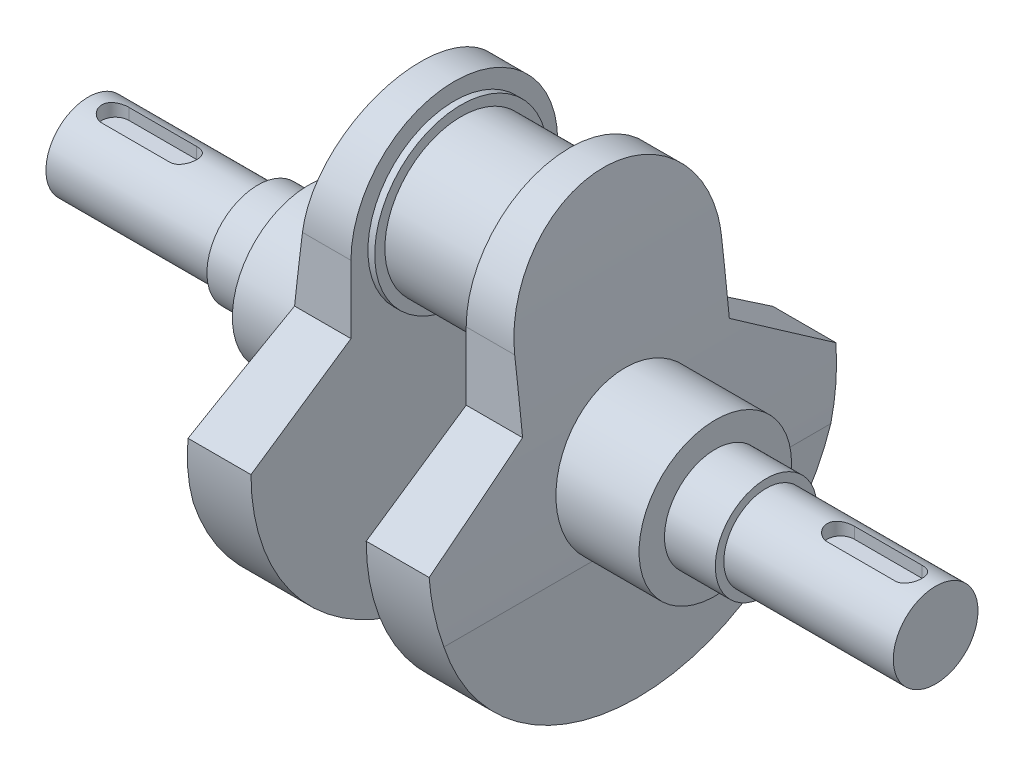
from build123d import *

# Parameters (mm, degrees)
SKETCH1_R           = 22.5
BOSS_EXTRUDE1_DEPTH = 15
SKETCH2_R           = 25.5
BOSS_EXTRUDE2_DEPTH = 2
BOSS_EXTRUDE3_DEPTH = 20
CUT_EXTRUDE1_DEPTH  = 99
BOSS_EXTRUDE4_REACH = 77
SKETCH5_R           = 22.5
SKETCH6_R           = 15
BOSS_EXTRUDE5_DEPTH = 15
SKETCH7_R           = 12.5
BOSS_EXTRUDE6_DEPTH = 50
CUT_EXTRUDE2_DEPTH  = 4


with BuildPart() as part:
    # Sketch1 → Boss-Extrude1 (new body, symmetric)
    with BuildSketch(Plane(origin=(0, 0, 0), x_dir=(0, 0, -1), z_dir=(1, 0, 0))):
        Circle(SKETCH1_R)
    extrude(amount=BOSS_EXTRUDE1_DEPTH, both=True)

    # Sketch2 → Boss-Extrude2 (add)
    with BuildSketch(Plane(origin=(15, 0, 0), x_dir=(0, 0, -1), z_dir=(1, 0, 0))):
        Circle(SKETCH2_R)
    extrude(amount=BOSS_EXTRUDE2_DEPTH)

    # Sketch3 → Boss-Extrude3 (add)
    with BuildSketch(Plane(origin=(17, 0, 0), x_dir=(0, 0, -1), z_dir=(1, 0, 0))):
        with BuildLine():
            Line((-30.5, 0), (-30.5, -20))
            Line((-30.5, -20), (-60, -40))
            ThreePointArc((-60, -40), (0, -100), (60, -40))
            Line((60, -40), (30.5, -20))
            Line((30.5, -20), (30.5, 0))
            ThreePointArc((30.5, 0), (0, 30.5), (-30.5, 0))
        make_face()
    extrude(amount=BOSS_EXTRUDE3_DEPTH)

    # Sketch4 → Cut-Extrude1 (cut, symmetric)
    with BuildSketch(Plane.XY):
        with BuildLine():
            Line((27, 30.5), (37, 30.5))
            Line((37, 30.5), (37, -58.5))
            ThreePointArc((37, -58.5), (32.963579083, -13.891732687), (27, 30.5))
        make_face()
    extrude(amount=CUT_EXTRUDE1_DEPTH, both=True, mode=Mode.SUBTRACT)

    # Sketch5 → Boss-Extrude4 (add, up to next)
    with BuildSketch(Plane(origin=(60, 0, 0), x_dir=(0, 0, -1), z_dir=(1, 0, 0)), mode=Mode.PRIVATE) as boss_extrude4_sk1:
        with Locations((0, -40)):
            Circle(SKETCH5_R)
    boss_extrude4_tool1 = extrude(boss_extrude4_sk1.sketch, amount=-BOSS_EXTRUDE4_REACH, mode=Mode.PRIVATE) - part.part
    add(boss_extrude4_tool1.solids().sort_by_distance((60, -40, 0))[0])

    # Sketch6 → Boss-Extrude5 (add)
    with BuildSketch(Plane(origin=(60, 0, 0), x_dir=(0, 0, -1), z_dir=(1, 0, 0))):
        with Locations((0, -40)):
            Circle(SKETCH6_R)
    extrude(amount=BOSS_EXTRUDE5_DEPTH)

    # Sketch7 → Boss-Extrude6 (add)
    with BuildSketch(Plane(origin=(75, 0, 0), x_dir=(0, 0, -1), z_dir=(1, 0, 0))):
        with Locations((0, -40)):
            Circle(SKETCH7_R)
    extrude(amount=BOSS_EXTRUDE6_DEPTH)

    # Sketch9 → Cut-Extrude2 (cut)
    with BuildSketch(Plane(origin=(0, -27.5, 0), x_dir=(-1, 0, 0), z_dir=(0, 1, 0))):
        with BuildLine():
            Line((-97, -4), (-117, -4))
            ThreePointArc((-117, -4), (-121, 0), (-117, 4))
            Line((-117, 4), (-97, 4))
            ThreePointArc((-97, 4), (-93, 0), (-97, -4))
        make_face()
    extrude(amount=-CUT_EXTRUDE2_DEPTH, mode=Mode.SUBTRACT)

    # Mirror2: part across plane


with BuildPart() as part_1:
    add(part.part)
    add(part.part.mirror(Plane(origin=(0, 0, 0), x_dir=(0, 0, 1), z_dir=(1, 0, 0))))


solid = part_1.part
